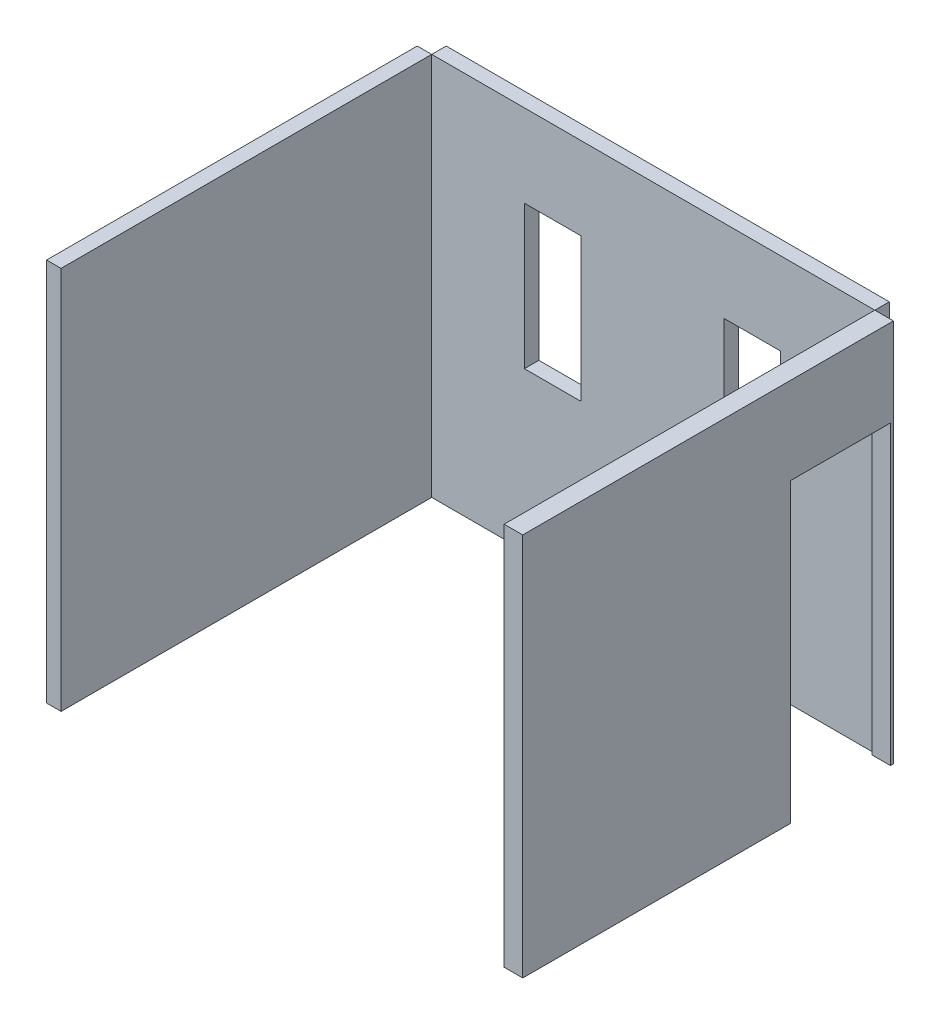
from build123d import *

# Parameters (mm, degrees)
ESBO_O6_W                = 3060
ESBO_O6_H                = 2650
RESSALTO_EXTRUS_O2_DEPTH = 100
ESBO_O7_W                = 390
ESBO_O7_H                = 990
CORTE_EXTRUS_O1_DEPTH    = 749
ESBO_O8_W                = 100
ESBO_O8_H                = 2650
RESSALTO_EXTRUS_O3_DEPTH = 2560
ESBO_O9_W                = 128.55153638
ESBO_O9_H                = 2650
RESSALTO_EXTRUS_O4_DEPTH = 2560
ESBO_O12_W               = 690
ESBO_O12_H               = 2050
CORTE_EXTRUS_O2_DEPTH    = 1050


with BuildPart() as part:
    # Esboço6 → Ressalto-extrusão2 (new body)
    with BuildSketch(Plane.XY):
        with Locations((1530, 1325)):
            Rectangle(ESBO_O6_W, ESBO_O6_H)
    extrude(amount=RESSALTO_EXTRUS_O2_DEPTH)

    # Esboço7 → Corte-extrusão1 (cut)
    with BuildSketch(Plane.XY.offset(100)):
        with Locations((2215, 1585)):
            Rectangle(ESBO_O7_W, ESBO_O7_H)
        with Locations((835, 1585)):
            Rectangle(ESBO_O7_W, ESBO_O7_H)
    extrude(amount=-CORTE_EXTRUS_O1_DEPTH, mode=Mode.SUBTRACT)


with BuildPart() as body_2:
    # Esboço8 → Ressalto-extrusão3 (new body)
    with BuildSketch(Plane.XY.offset(100)):
        with Locations((-50, 1325)):
            Rectangle(ESBO_O8_W, ESBO_O8_H)
    extrude(amount=RESSALTO_EXTRUS_O3_DEPTH)


with BuildPart() as body_3:
    # Esboço9 → Ressalto-extrusão4 (new body)
    with BuildSketch(Plane.XY.offset(100)):
        with Locations((3124.27576819, 1325)):
            Rectangle(ESBO_O9_W, ESBO_O9_H)
    extrude(amount=RESSALTO_EXTRUS_O4_DEPTH)

    # Esboço12 → Corte-extrusão2 (cut)
    with BuildSketch(Plane(origin=(3188.55153638, 0, 0), x_dir=(0, 0, -1), z_dir=(1, 0, 0))):
        with Locations((-465, 1025)):
            Rectangle(ESBO_O12_W, ESBO_O12_H)
    extrude(amount=-CORTE_EXTRUS_O2_DEPTH, mode=Mode.SUBTRACT)


solid = Compound([part.part, body_2.part, body_3.part])
